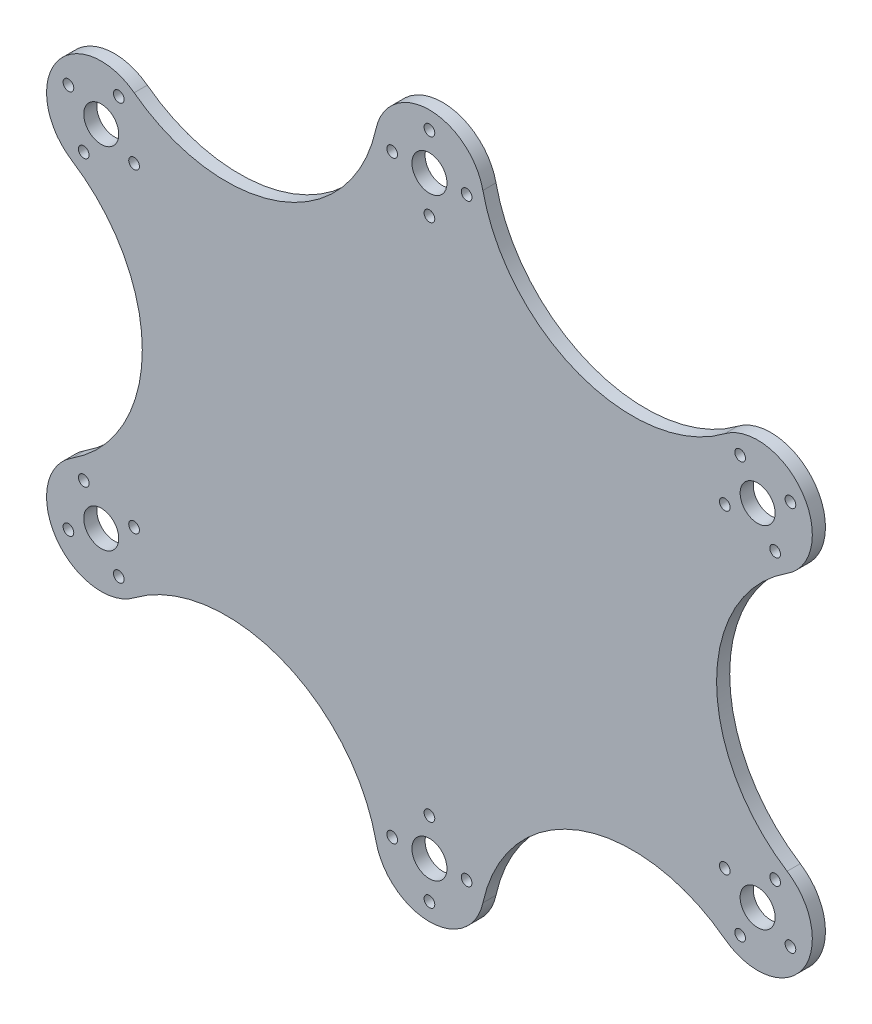
from build123d import *

# Parameters (mm, degrees)
SKETCH2_R           = 4
SKETCH2_R_2         = 1.22
BOSS_EXTRUDE2_DEPTH = 3


with BuildPart() as part:
    # Sketch2 → Boss-Extrude2 (new body)
    with BuildSketch(Plane.XY):
        with BuildLine():
            ThreePointArc((-37.264221934, 51.570757137), (-55.048861675, 48.724809542), (-51.528144835, 31.061361936))
            ThreePointArc((-51.528144835, 31.061361936), (-35.404106773, 1.587677725), (-51.528144835, -27.886006485))
            ThreePointArc((-51.528144835, -27.886006485), (-55.048861675, -45.549454092), (-37.264221934, -48.395401687))
            ThreePointArc((-37.264221934, -48.395401687), (-4.021715205, -43.53552404), (17.99893596, -68.90821776))
            ThreePointArc((17.99893596, -68.90821776), (30.213270142, -78.751144089), (42.427604324, -68.90821776))
            ThreePointArc((42.427604324, -68.90821776), (64.448255489, -43.53552404), (97.690762219, -48.395401687))
            ThreePointArc((97.690762219, -48.395401687), (115.475401959, -45.549454092), (111.95468512, -27.886006485))
            ThreePointArc((111.95468512, -27.886006485), (95.830647057, 1.587677725), (111.95468512, 31.061361936))
            ThreePointArc((111.95468512, 31.061361936), (115.475401959, 48.724809542), (97.690762219, 51.570757137))
            ThreePointArc((97.690762219, 51.570757137), (64.448255489, 46.71087949), (42.427604324, 72.08357321))
            ThreePointArc((42.427604324, 72.08357321), (30.213270142, 81.926499539), (17.99893596, 72.08357321))
            ThreePointArc((17.99893596, 72.08357321), (-4.021715205, 46.71087949), (-37.264221934, 51.570757137))
        make_face()
        with Locations((-44.786729858, 41.587677725)):
            Circle(SKETCH2_R, mode=Mode.SUBTRACT)
        with Locations((30.213270142, 69.426499539)):
            Circle(SKETCH2_R, mode=Mode.SUBTRACT)
        with Locations((105.213270142, 41.587677725)):
            Circle(SKETCH2_R, mode=Mode.SUBTRACT)
        with Locations((105.213270142, -38.412322275)):
            Circle(SKETCH2_R, mode=Mode.SUBTRACT)
        with Locations((30.213270142, -66.251144089)):
            Circle(SKETCH2_R, mode=Mode.SUBTRACT)
        with Locations((-44.786729858, -38.412322275)):
            Circle(SKETCH2_R, mode=Mode.SUBTRACT)
        with Locations((30.213270142, 77.926499539)):
            Circle(SKETCH2_R_2, mode=Mode.SUBTRACT)
        with Locations((21.713270142, 69.426499539)):
            Circle(SKETCH2_R_2, mode=Mode.SUBTRACT)
        with Locations((30.213270142, 60.926499539)):
            Circle(SKETCH2_R_2, mode=Mode.SUBTRACT)
        with Locations((38.713270142, 69.426499539)):
            Circle(SKETCH2_R_2, mode=Mode.SUBTRACT)
        with Locations((-40.786729858, 49.087677725)):
            Circle(SKETCH2_R_2, mode=Mode.SUBTRACT)
        with Locations((-37.286729858, 37.587677725)):
            Circle(SKETCH2_R_2, mode=Mode.SUBTRACT)
        with Locations((-48.786729858, 34.087677725)):
            Circle(SKETCH2_R_2, mode=Mode.SUBTRACT)
        with Locations((-52.286729858, 45.587677725)):
            Circle(SKETCH2_R_2, mode=Mode.SUBTRACT)
        with Locations((-37.286729858, -34.412322275)):
            Circle(SKETCH2_R_2, mode=Mode.SUBTRACT)
        with Locations((-48.786729858, -30.912322275)):
            Circle(SKETCH2_R_2, mode=Mode.SUBTRACT)
        with Locations((-40.786729858, -45.912322275)):
            Circle(SKETCH2_R_2, mode=Mode.SUBTRACT)
        with Locations((-52.286729858, -42.412322275)):
            Circle(SKETCH2_R_2, mode=Mode.SUBTRACT)
        with Locations((112.713270142, -42.412322275)):
            Circle(SKETCH2_R_2, mode=Mode.SUBTRACT)
        with Locations((101.213270142, -45.912322275)):
            Circle(SKETCH2_R_2, mode=Mode.SUBTRACT)
        with Locations((97.713270142, -34.412322275)):
            Circle(SKETCH2_R_2, mode=Mode.SUBTRACT)
        with Locations((109.213270142, -30.912322275)):
            Circle(SKETCH2_R_2, mode=Mode.SUBTRACT)
        with Locations((97.713270142, 37.587677725)):
            Circle(SKETCH2_R_2, mode=Mode.SUBTRACT)
        with Locations((109.213270142, 34.087677725)):
            Circle(SKETCH2_R_2, mode=Mode.SUBTRACT)
        with Locations((101.213270142, 49.087677725)):
            Circle(SKETCH2_R_2, mode=Mode.SUBTRACT)
        with Locations((112.713270142, 45.587677725)):
            Circle(SKETCH2_R_2, mode=Mode.SUBTRACT)
        with Locations((30.213270142, -57.751144089)):
            Circle(SKETCH2_R_2, mode=Mode.SUBTRACT)
        with Locations((38.713270142, -66.251144089)):
            Circle(SKETCH2_R_2, mode=Mode.SUBTRACT)
        with Locations((21.713270142, -66.251144089)):
            Circle(SKETCH2_R_2, mode=Mode.SUBTRACT)
        with Locations((30.213270142, -74.751144089)):
            Circle(SKETCH2_R_2, mode=Mode.SUBTRACT)
    extrude(amount=BOSS_EXTRUDE2_DEPTH)


solid = part.part
